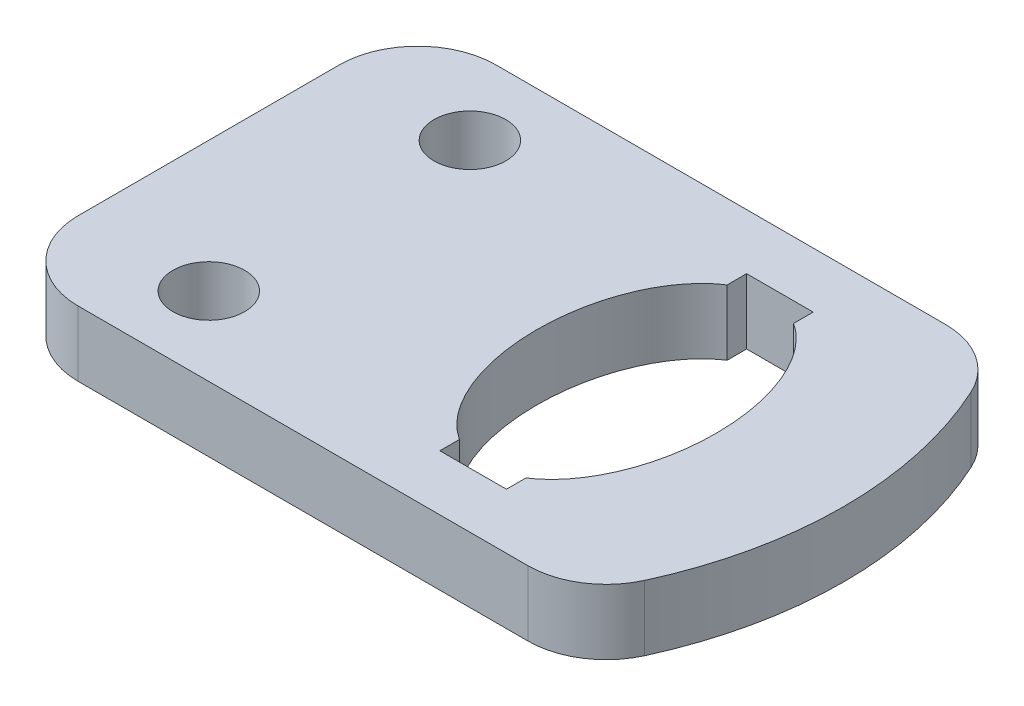
from build123d import *

# Parameters (mm, degrees)
SKETCH1_W           = 44
SKETCH1_H           = 5
BOSS_EXTRUDE1_DEPTH = 32
SKETCH2_R           = 2.75
CUT_EXTRUDE1_DEPTH  = 6
BOSS_EXTRUDE2_DEPTH = 5
FILLET1_R           = 6


with BuildPart() as part:
    # Sketch1 → Boss-Extrude1 (new body)
    with BuildSketch(Plane.XY):
        with Locations((22, -2.5)):
            Rectangle(SKETCH1_W, SKETCH1_H)
    extrude(amount=BOSS_EXTRUDE1_DEPTH)

    # Sketch2 → Cut-Extrude1 (cut, through all)
    with BuildSketch(Plane.XZ.offset(5)):
        with Locations((10, 26)):
            Circle(SKETCH2_R)
        with Locations((10, 6)):
            Circle(SKETCH2_R)
        with BuildLine():
            Line((29.45, 5.75), (29.45, 4.25))
            Line((29.45, 4.25), (34.55, 4.25))
            Line((34.55, 4.25), (34.55, 5.75))
            add(Edge.make_bspline(
                [(34.55, 5.75), (50.535539216, 16), (34.55, 26.25)],
                knots=[3.521580401, 3.521580401, 3.521580401, 5.90319756, 5.90319756, 5.90319756], degree=2, weights=[1, 0.370909091, 1]))
            Line((34.55, 26.25), (34.55, 27.75))
            Line((34.55, 27.75), (29.45, 27.75))
            Line((29.45, 27.75), (29.45, 26.25))
            add(Edge.make_bspline(
                [(29.45, 26.25), (13.464460784, 16), (29.45, 5.75)],
                knots=[0.379987747, 0.379987747, 0.379987747, 2.761604906, 2.761604906, 2.761604906], degree=2, weights=[1, 0.370909091, 1]))
        make_face()
    extrude(amount=-CUT_EXTRUDE1_DEPTH, mode=Mode.SUBTRACT)

    # Sketch3 → Boss-Extrude2 (add)
    with BuildSketch(Plane.XZ.offset(5)):
        with BuildLine():
            Line((44, 32), (44, 0))
            ThreePointArc((44, 0), (48.622844919, 16), (44, 32))
        make_face()
    extrude(amount=-BOSS_EXTRUDE2_DEPTH)

    # Fillet1
    fillet1_edges = [part.edges().sort_by_distance(p)[0] for p in [
        (0, -2.5, 32),
        (44, -2.5, 32),
        (0, -2.5, 0),
        (44, -2.5, 0),
    ]]
    fillet(fillet1_edges, radius=FILLET1_R)


solid = part.part
